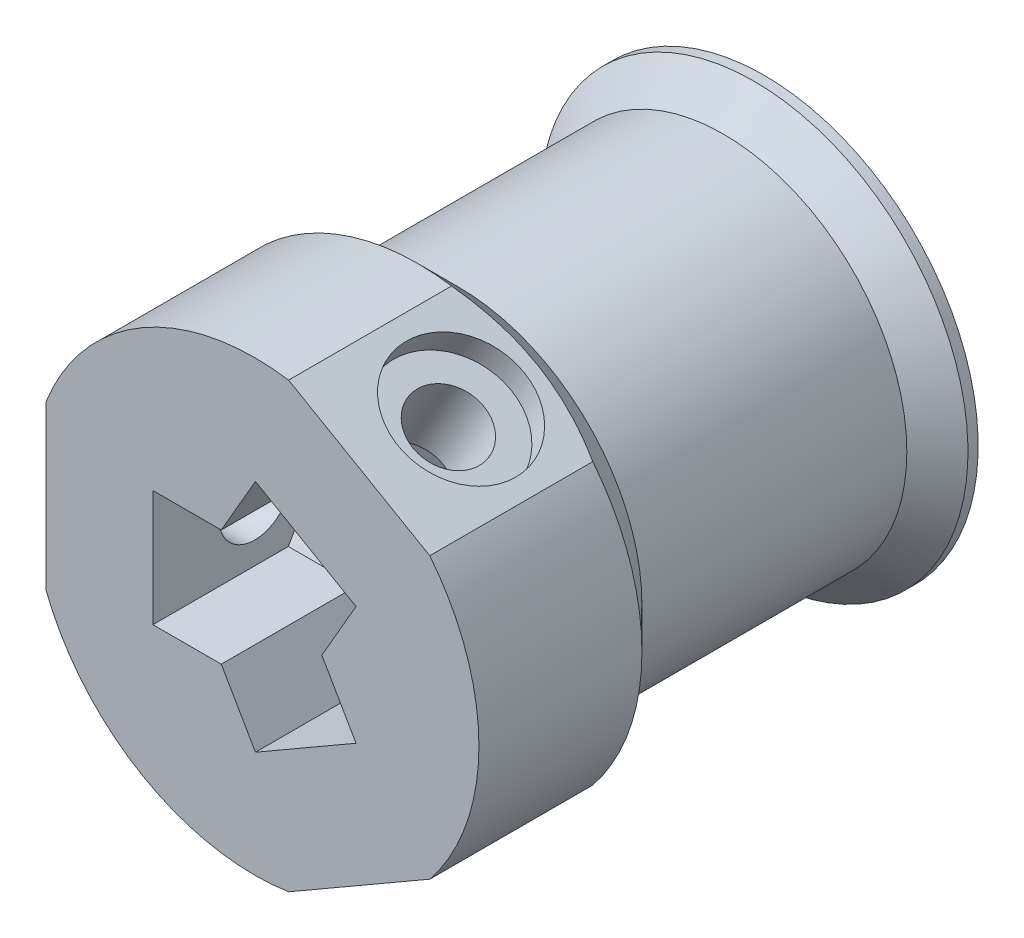
from build123d import *

# Parameters (mm, degrees)
SKETCH1_R                     = 11
BOSS_BASE_FLANGE_DEPTH        = 2
BOSS_BASE_FLANGE_TAPER        = 45
SKETCH2_R                     = 9
BOSS_SPECTRA_SPOOL_DEPTH      = 13
SKETCH3_R                     = 9
BOSS_TOP_FLANGE_DEPTH         = 2
BOSS_TOP_FLANGE_DRAFT         = -45
SKETCH4_R                     = 11
BOSS_TOP_EXTENSION_DEPTH      = 8
SKETCH5_R                     = 2.6
CUT_STEPPER_SHAFT_DEPTH       = 30.444863729
CUT_SET_SCREW_HOLE_REACH      = 37.071
CUT_SET_SCREW_HOLE_END_RADIUS = 2.6
SKETCH7_R                     = 1.75
SKETCH8_R                     = 3.1
CUT_SCREW_HEAD_SLOT_DEPTH     = 2
CUT_FLATEN_REACH              = 31.445
SKETCH6_W                     = 0.753049234
SKETCH6_H                     = 8
CUT_NUT_HOLE_DEPTH            = 5
SKETCH11_W                    = 3.354551733
SKETCH11_H                    = 5.7
CUT_NUT_SLOT_DEPTH            = 5
CIRPATTERN1_COUNT             = 3
CUT_THREAD_HOLE_DEPTH         = 30.444863729
SKETCH15_W                    = 1.5
SKETCH15_H                    = 1
CUT_EXTRUDE8_DEPTH            = 28.81186797
CHAMFER1_SIZE                 = 1
CHAMFER1_SIZE2                = 0.707106781
CHAMFER3_SIZE                 = 0.3
CHAMFER3_SIZE2                = 0.519615242
SKETCH16_OUTSIDE_W            = 31.982
SKETCH16_OUTSIDE_H            = 31.982
SKETCH16_OUTSIDE_R            = 10.5
CUT_TRUNCATE_BASE_DEPTH       = 5
SKETCH8_2_R                   = 3.1
CUT_EXTRUDE9_DEPTH            = 3


with BuildPart() as part:
    # Sketch1 → Boss-Base Flange (new body)
    with BuildSketch(Plane.XY):
        Circle(SKETCH1_R)
    extrude(amount=BOSS_BASE_FLANGE_DEPTH, taper=BOSS_BASE_FLANGE_TAPER)

    # Sketch2 → Boss-Spectra Spool (add)
    with BuildSketch(Plane.XY.offset(2)):
        with Locations(Location((0, 0, 0), (0, 0, 180))):
            Circle(SKETCH2_R)
    extrude(amount=BOSS_SPECTRA_SPOOL_DEPTH)


with BuildPart() as boss_top_flange_tool:
    # Sketch3 → Boss-Top Flange (with draft: the straight prism first)
    with BuildSketch(Plane.XY.offset(15)):
        with Locations(Location((0, 0, 0), (0, 0, 180))):
            Circle(SKETCH3_R)
    extrude(amount=BOSS_TOP_FLANGE_DEPTH)
    # Boss-Top Flange: the draft: its side faces are tilted about the plane it starts from
    boss_top_flange_sides = [boss_top_flange_tool.faces().sort_by_distance(p)[0] for p in [
        (9, 0, 16),
    ]]
    draft(boss_top_flange_sides, Plane.XY.offset(15), BOSS_TOP_FLANGE_DRAFT)


with BuildPart() as part_1:
    add(part.part)

    # Boss-Top Flange: add boss_top_flange_tool
    add(boss_top_flange_tool.part)

    # Sketch4 → Boss-Top Extension (add)
    with BuildSketch(Plane.XY.offset(17)):
        Circle(SKETCH4_R)
    extrude(amount=BOSS_TOP_EXTENSION_DEPTH)

    # Sketch5 → Cut-Stepper Shaft (cut, through all)
    with BuildSketch(Plane(origin=(0, 0, 0), x_dir=(-1, 0, 0), z_dir=(0, 0, -1))):
        Circle(SKETCH5_R)
    extrude(amount=-CUT_STEPPER_SHAFT_DEPTH, mode=Mode.SUBTRACT)

    # Cut-Set Screw Hole: up to this cylinder (the profile starts outside it)
    cut_set_screw_hole_end = Plane(origin=(0, 0, 20), z_dir=(0, 0, -1)) * Cylinder(CUT_SET_SCREW_HOLE_END_RADIUS, 80.342, mode=Mode.PRIVATE)
    # Sketch7 → Cut-Set Screw Hole (cut, up to the surface)
    with BuildSketch(Plane(origin=(-11, 0, 0), x_dir=(0, 0, -1), z_dir=(1, 0, 0)), mode=Mode.PRIVATE) as cut_set_screw_hole_sk1:
        with Locations(Location((-20, 0, 0), (0, 0, 180))):
            Circle(SKETCH7_R)
    cut_set_screw_hole_tool1 = extrude(cut_set_screw_hole_sk1.sketch, amount=CUT_SET_SCREW_HOLE_REACH, mode=Mode.PRIVATE) - cut_set_screw_hole_end
    cut_set_screw_hole = cut_set_screw_hole_tool1.solids().sort_by_distance((-11, 0, 20))[0]
    add(cut_set_screw_hole, mode=Mode.SUBTRACT)

    # Sketch8 → Cut-Screw Head Slot (cut)
    with BuildSketch(Plane(origin=(-11, 0, 0), x_dir=(0, 0, -1), z_dir=(1, 0, 0))):
        with Locations(Location((-20, 0, 0), (0, 0, 194.592594316))):
            Circle(SKETCH8_R)
    cut_screw_head_slot = extrude(amount=CUT_SCREW_HEAD_SLOT_DEPTH, mode=Mode.SUBTRACT)

    # Cut-Flaten: up to this cone (the profile starts inside it)
    cut_flaten_end = Plane(origin=(0, 0, 25), z_dir=(0, 0, 1)).offset(-18.999999) * Cone(1e-06, 69.945, 69.944999, align=(Align.CENTER, Align.CENTER, Align.MIN), mode=Mode.PRIVATE)
    # Sketch6 → Cut-Flaten (cut, up to the surface)
    with BuildSketch(Plane.XY.offset(25), mode=Mode.PRIVATE) as cut_flaten_sk1:
        with Locations((-10.623475383, 0)):
            Rectangle(SKETCH6_W, SKETCH6_H)
    cut_flaten_tool1 = extrude(cut_flaten_sk1.sketch, amount=-CUT_FLATEN_REACH, mode=Mode.PRIVATE) & cut_flaten_end
    cut_flaten = cut_flaten_tool1.solids().sort_by_distance((-10.623475, 0, 25))[0]
    add(cut_flaten, mode=Mode.SUBTRACT)

    # Sketch10 → Cut-Nut Hole (cut)
    with BuildSketch(Plane.ZY):
        Polygon((23.290896534, 0), (21.645448267, 2.85), (18.354551733, 2.85), (16.709103466, 0), (18.354551733, -2.85), (21.645448267, -2.85), align=None)
    cut_nut_hole = extrude(amount=CUT_NUT_HOLE_DEPTH, mode=Mode.SUBTRACT)

    # Sketch11 → Cut-Nut Slot (cut)
    with BuildSketch(Plane.ZY):
        with Locations((23.322724134, 0)):
            Rectangle(SKETCH11_W, SKETCH11_H)
    cut_nut_slot = extrude(amount=CUT_NUT_SLOT_DEPTH, mode=Mode.SUBTRACT)

    # CirPattern1: Cut-Set Screw Hole, Cut-Screw Head Slot, Cut-Flaten, Cut-Nut Hole, Cut-Nut Slot ×3 about axis
    cirpattern1_axis = Axis((0, 0, 0), (0, 0, 1))
    add([cut_set_screw_hole.rotate(cirpattern1_axis, i * 360 / CIRPATTERN1_COUNT) for i in range(1, CIRPATTERN1_COUNT)], mode=Mode.SUBTRACT)
    add([cut_screw_head_slot.rotate(cirpattern1_axis, i * 360 / CIRPATTERN1_COUNT) for i in range(1, CIRPATTERN1_COUNT)], mode=Mode.SUBTRACT)
    add([cut_flaten.rotate(cirpattern1_axis, i * 360 / CIRPATTERN1_COUNT) for i in range(1, CIRPATTERN1_COUNT)], mode=Mode.SUBTRACT)
    add([cut_nut_hole.rotate(cirpattern1_axis, i * 360 / CIRPATTERN1_COUNT) for i in range(1, CIRPATTERN1_COUNT)], mode=Mode.SUBTRACT)
    add([cut_nut_slot.rotate(cirpattern1_axis, i * 360 / CIRPATTERN1_COUNT) for i in range(1, CIRPATTERN1_COUNT)], mode=Mode.SUBTRACT)

    # Sketch13 → Cut-Thread Hole (cut, through all)
    with BuildSketch(Plane.XY.offset(25)):
        Polygon((-4.066025404, 1), (-4.932050808, 0.5), (-4.932050808, -0.5), (-4.066025404, -1), (-3.2, -0.5), (-3.2, 0.5), align=None)
    extrude(amount=-CUT_THREAD_HOLE_DEPTH, mode=Mode.SUBTRACT)

    # Sketch15 → Cut-Extrude8 (cut, symmetric)
    with BuildSketch(Plane(origin=(-5.5, 0, 5.5), x_dir=(0.7071067811865464, 0, 0.7071067811865488), z_dir=(-0.7071067811865488, 0, 0.7071067811865464))):
        with Locations((-4.189918951, 0)):
            Rectangle(SKETCH15_W, SKETCH15_H)
    cut_extrude8 = extrude(amount=CUT_EXTRUDE8_DEPTH, both=True, mode=Mode.SUBTRACT)

    # Chamfer1
    chamfer1_edges = [part_1.edges().sort_by_distance(p)[0] for p in [
        (-4.932050808, 0, 0.067270773),
    ]]
    chamfer1_side = [part_1.faces().sort_by_distance(p)[0] for p in [
        (-6.963711629, 0, 2.098931595),
    ]]
    chamfer(chamfer1_edges, length=CHAMFER1_SIZE, length2=CHAMFER1_SIZE2, reference=chamfer1_side[0])

    # Mirror1: Cut-Extrude8 across plane
    add(cut_extrude8.mirror(Plane.XY.offset(8.5)), mode=Mode.SUBTRACT)

    # Chamfer3
    chamfer3_edges = [part_1.edges().sort_by_distance(p)[0] for p in [
        (2.6, 0, 0),
    ]]
    chamfer3_side = [part_1.faces().sort_by_distance(p)[0] for p in [
        (-10.688873016, 0, 0),
    ]]
    chamfer(chamfer3_edges, length=CHAMFER3_SIZE, length2=CHAMFER3_SIZE2, reference=chamfer3_side[0])

    # Sketch16 outside → Cut-Truncate Base (cut)
    with BuildSketch(Plane(origin=(0, 0, 0), x_dir=(-1, 0, 0), z_dir=(0, 0, -1))):
        Rectangle(SKETCH16_OUTSIDE_W, SKETCH16_OUTSIDE_H)
        Circle(SKETCH16_OUTSIDE_R, mode=Mode.SUBTRACT)
    extrude(amount=-CUT_TRUNCATE_BASE_DEPTH, mode=Mode.SUBTRACT)

    # Sketch8_2 → Cut-Extrude9 (cut)
    with BuildSketch(Plane(origin=(-11, 0, 0), x_dir=(0, 0, -1), z_dir=(1, 0, 0))):
        with Locations((-20, 0)):
            Circle(SKETCH8_2_R)
    extrude(amount=CUT_EXTRUDE9_DEPTH, mode=Mode.SUBTRACT)


solid = part_1.part
